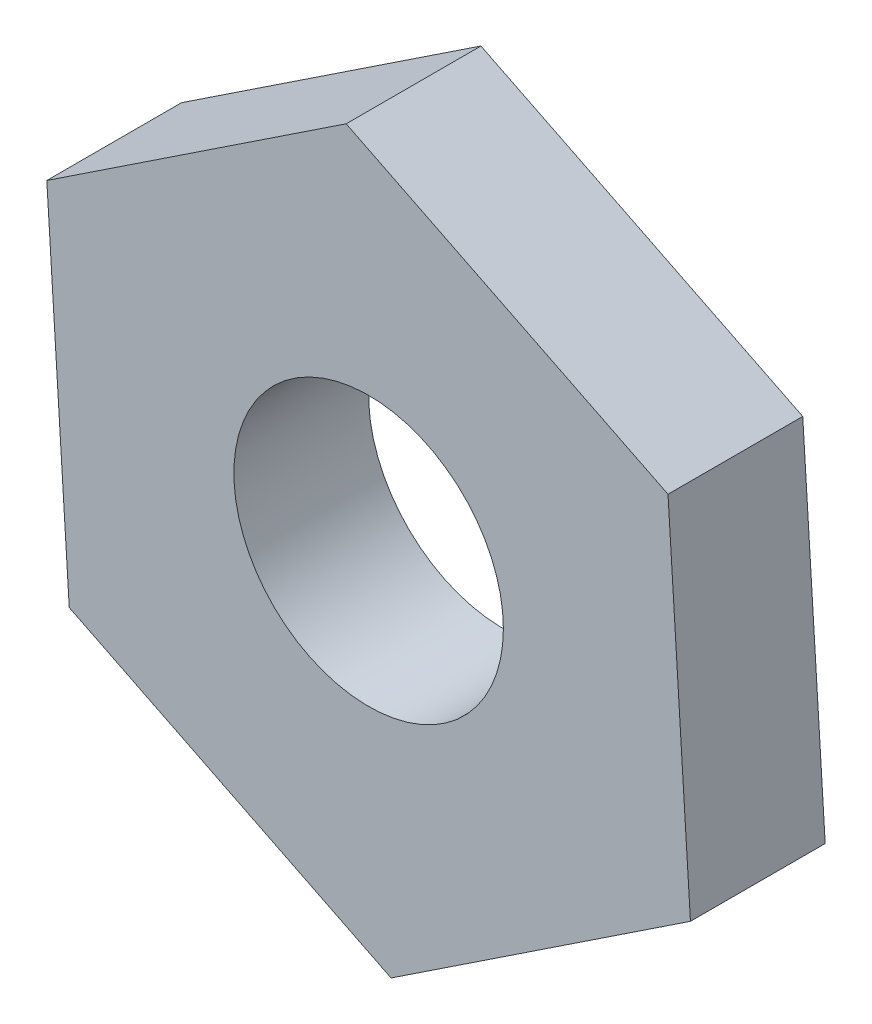
from build123d import *

# Parameters (mm, degrees)
BOSS_EXTRUDE1_DEPTH = 1.5
SKETCH2_R           = 1.5
CUT_EXTRUDE1_DEPTH  = 2.5


with BuildPart() as part:
    # Sketch1 → Boss-Extrude1 (new body)
    with BuildSketch(Plane.XY):
        Polygon((-3.332397475, -2.212493405), (0.249876757, -3.992187572), (3.582274232, -1.779694166), (3.332397475, 2.212493405), (-0.249876757, 3.992187572), (-3.582274232, 1.779694166), align=None)
    extrude(amount=BOSS_EXTRUDE1_DEPTH)

    # Sketch2 → Cut-Extrude1 (cut, through all)
    with BuildSketch(Plane.XY.offset(1.5)):
        Circle(SKETCH2_R)
    extrude(amount=-CUT_EXTRUDE1_DEPTH, mode=Mode.SUBTRACT)


solid = part.part
